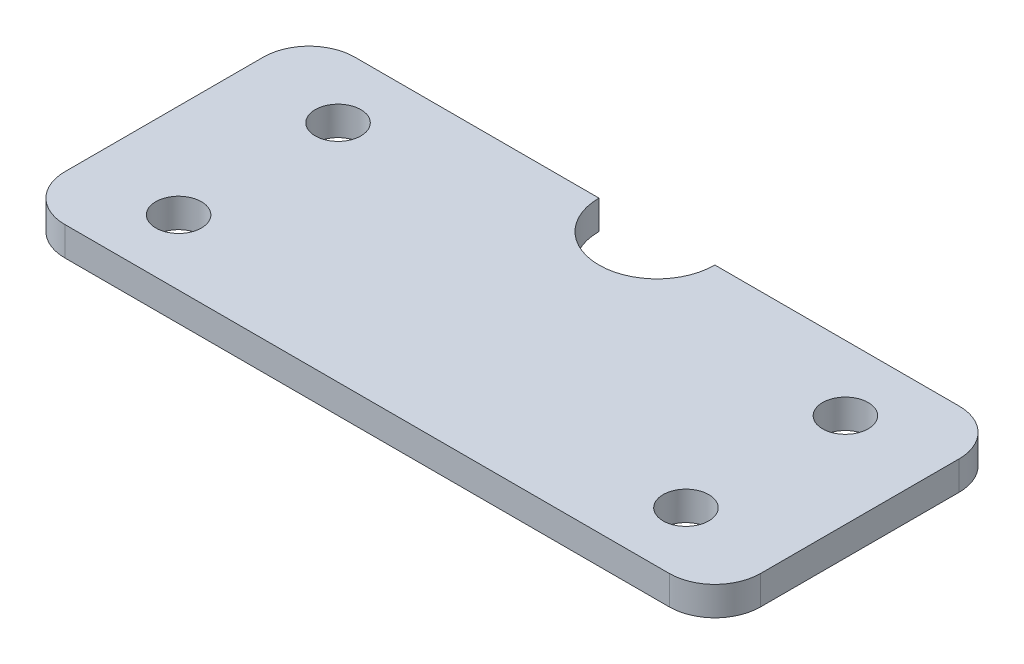
from build123d import *

# Parameters (mm, degrees)
SKETCH1_W           = 152.4
SKETCH1_H           = 63.5
BOSS_EXTRUDE1_DEPTH = 6.35
FILLET1_R           = 10
CUT_EXTRUDE4_DEPTH  = 6.35
SKETCH2_R           = 5
CUT_EXTRUDE5_DEPTH  = 10


with BuildPart() as part:
    # Sketch1 → Boss-Extrude1 (new body)
    with BuildSketch(Plane(origin=(0, 0, 0), x_dir=(1, 0, 0), z_dir=(0, 1, 0))):
        Rectangle(SKETCH1_W, SKETCH1_H)
    extrude(amount=BOSS_EXTRUDE1_DEPTH)

    # Fillet1
    fillet1_edges = [part.edges().sort_by_distance(p)[0] for p in [
        (76.2, 3.175, 31.75),
        (-76.2, 3.175, 31.75),
        (-76.2, 3.175, -31.75),
        (76.2, 3.175, -31.75),
    ]]
    fillet(fillet1_edges, radius=FILLET1_R)

    # Sketch3 → Cut-Extrude4 (cut)
    with BuildSketch(Plane(origin=(0, 6.35, 0), x_dir=(1, 0, 0), z_dir=(0, 1, 0))):
        with BuildLine():
            Line((-12.7, 31.75), (12.7, 31.75))
            ThreePointArc((12.7, 31.75), (0, 19.05), (-12.7, 31.75))
        make_face()
    extrude(amount=-CUT_EXTRUDE4_DEPTH, mode=Mode.SUBTRACT)

    # Sketch2 → Cut-Extrude5 (cut)
    with BuildSketch(Plane(origin=(0, 6.35, 0), x_dir=(1, 0, 0), z_dir=(0, 1, 0))):
        with Locations((-55.5625, 17.4625)):
            Circle(SKETCH2_R)
        with Locations((55.5625, 17.4625)):
            Circle(SKETCH2_R)
        with Locations((55.5625, -17.4625)):
            Circle(SKETCH2_R)
        with Locations((-55.5625, -17.4625)):
            Circle(SKETCH2_R)
    extrude(amount=-CUT_EXTRUDE5_DEPTH, mode=Mode.SUBTRACT)


solid = part.part
